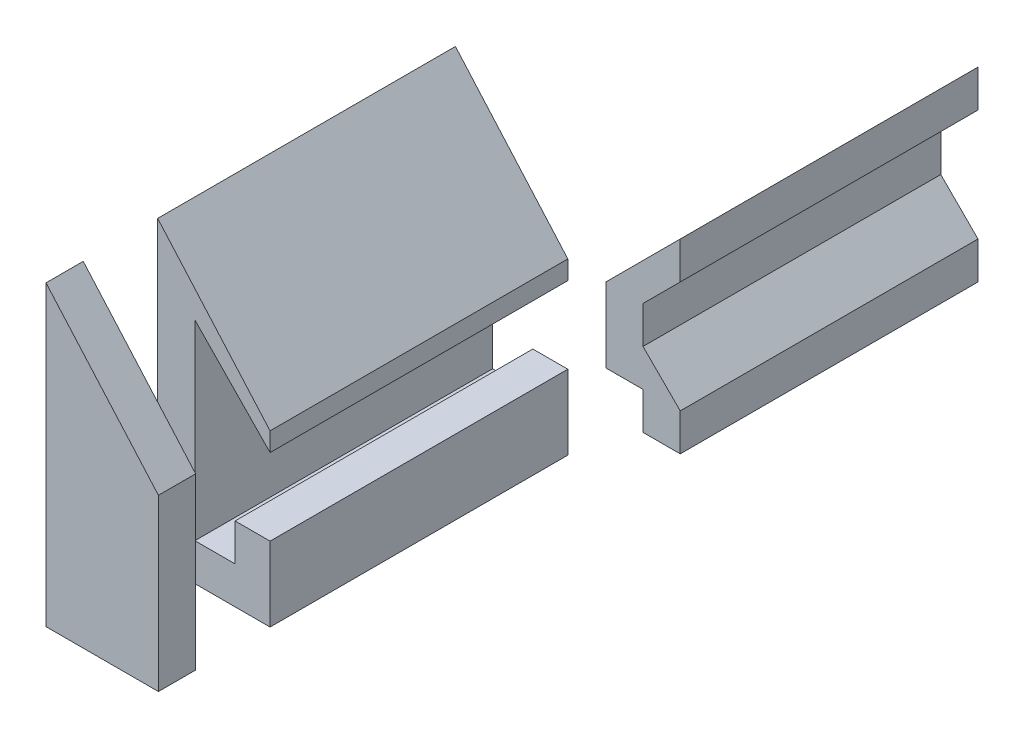
from build123d import *

# Parameters (mm, degrees)
BOSS_EXTRUDE1_DEPTH = 40
BOSS_EXTRUDE2_DEPTH = 5
BOSS_EXTRUDE3_DEPTH = 40


with BuildPart() as part:
    # Sketch2 → Boss-Extrude1 (new body)
    with BuildSketch(Plane.XY):
        Polygon((-0.1, -0.2), (-0.1, -10.2), (-15.2, -10.2), (-15.2, 29.8), (-0.1, 12.631933622), (-0.1, 10.102772968), (-10.2, 20.482842712), (-10.2, -5.2), (-4.8, -5.2), (-4.8, -0.2), align=None)
    extrude(amount=BOSS_EXTRUDE1_DEPTH)


with BuildPart() as body_2:
    # Sketch3 → Boss-Extrude2 (new body)
    with BuildSketch(Plane.XY.offset(50)):
        Polygon((-0.1, -0.2), (-0.1, 10.102772968), (-0.1, 12.631933622), (-15.2, 29.8), (-15.2, -10.2), (-0.1, -10.2), align=None)
    extrude(amount=BOSS_EXTRUDE2_DEPTH)


with BuildPart() as body_3:
    # Sketch4 → Boss-Extrude3 (new body)
    with BuildSketch(Plane(origin=(0, 0, -10), x_dir=(-1, 0, 0), z_dir=(0, 0, -1))):
        Polygon((5, 2.5), (-5, 12.5), (-5, 7.5), (0, 2.5), (0, -2.5), (-5, -7.5), (-5, -12.5), (0, -12.5), (0, -7.5), (5, -7.5), align=None)
    extrude(amount=BOSS_EXTRUDE3_DEPTH)


solid = Compound([part.part, body_2.part, body_3.part])
